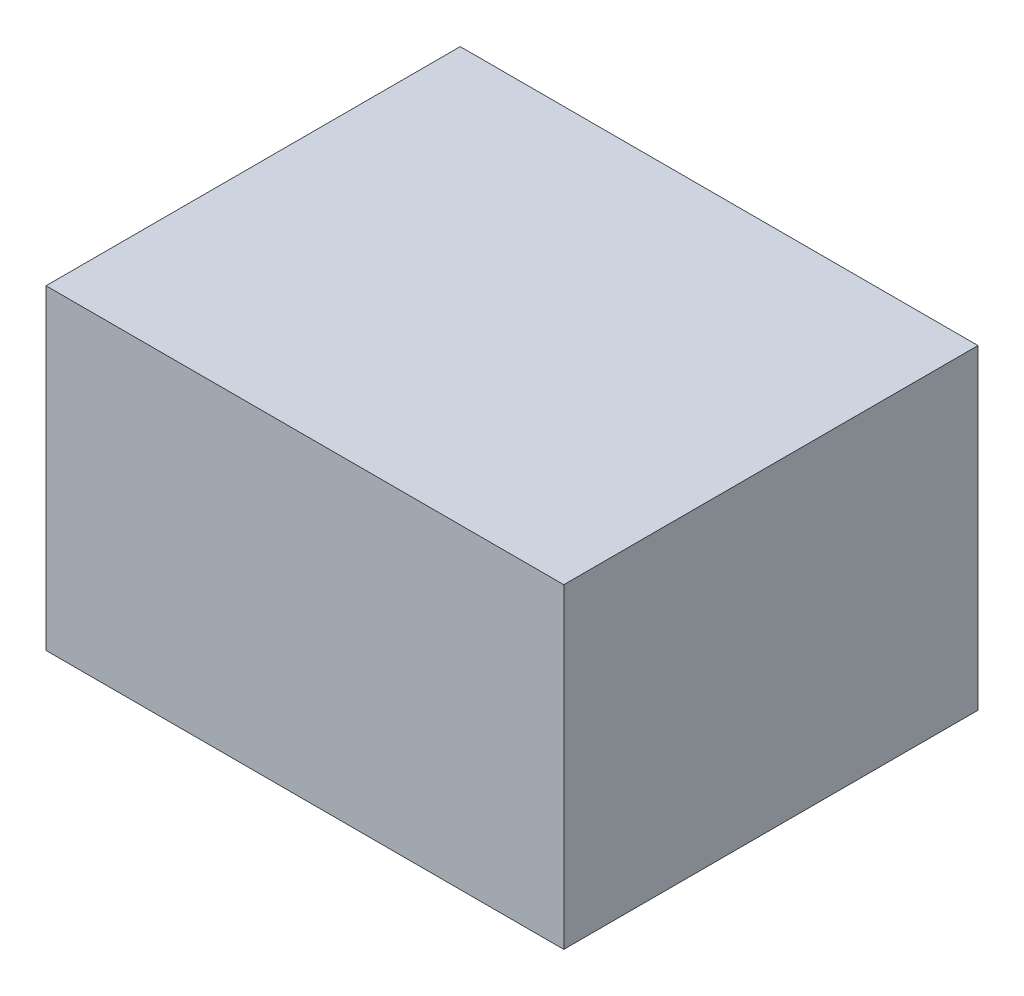
from build123d import *

# Parameters (mm, degrees)
SKETCH1_W           = 5
SKETCH1_H           = 4
BOSS_EXTRUDE1_DEPTH = 3.05


with BuildPart() as part:
    # Sketch1 → Boss-Extrude1 (new body)
    with BuildSketch(Plane(origin=(0, 0, 0), x_dir=(1, 0, 0), z_dir=(0, 1, 0))):
        Rectangle(SKETCH1_W, SKETCH1_H)
    extrude(amount=BOSS_EXTRUDE1_DEPTH)


solid = part.part
